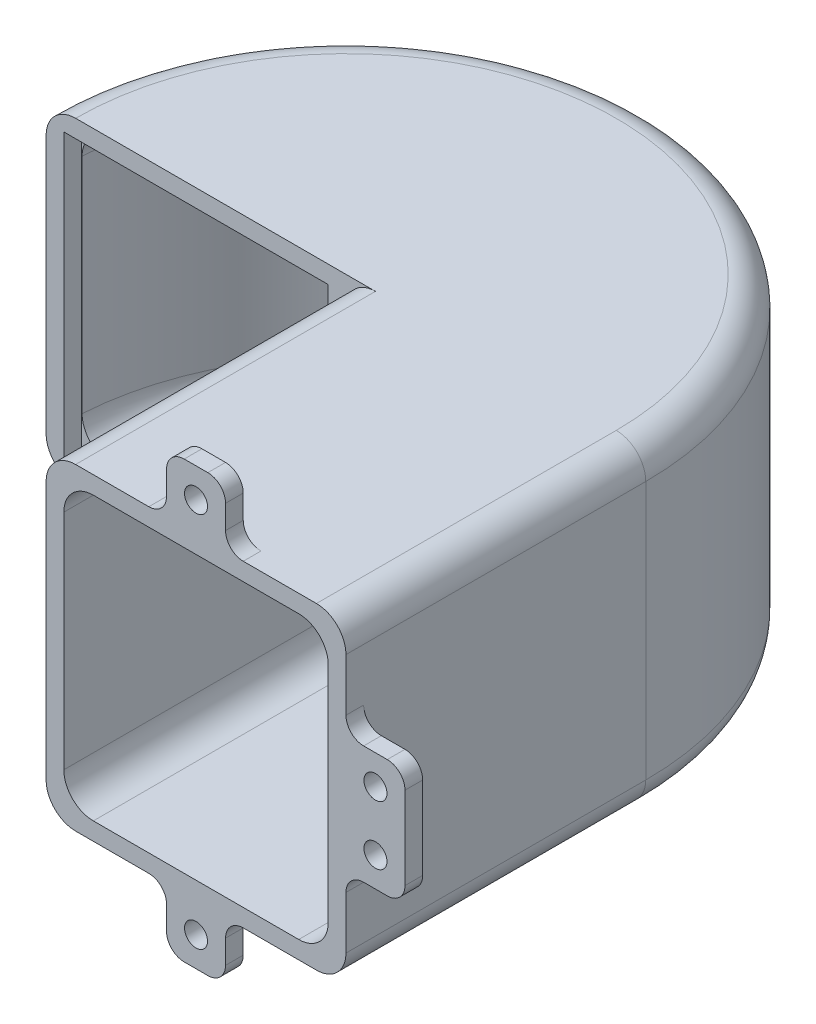
from build123d import *

# Parameters (mm, degrees)
BOSS_EXTRUDE1_DEPTH              = 50.8
CUT_EXTRUDE1_DEPTH               = 47.8
BOSS_EXTRUDE2_DEPTH              = 3
SKETCH4_W                        = 44.8
SKETCH4_H                        = 47.8
CUT_EXTRUDE2_DEPTH               = 3
SKETCH5_W                        = 44.8
SKETCH5_H                        = 47.8
CUT_EXTRUDE3_DEPTH               = 3
SKETCH6_W                        = 10
SKETCH6_H                        = 10
SKETCH6_H_2                      = 20
BOSS_EXTRUDE3_DEPTH              = 3
FILLET1_R                        = 5
FILLET2_R                        = 3
M3_5_CLEARANCE_HOLE2_D           = 3.9
M3_5_CLEARANCE_HOLE2_CSINK_D     = 3.95
M3_5_CLEARANCE_HOLE2_CSINK_ANGLE = 90


with BuildPart() as part:
    # Sketch1 → Boss-Extrude1 (new body)
    with BuildSketch(Plane(origin=(0, 0, 0), x_dir=(1, 0, 0), z_dir=(0, 1, 0))):
        with BuildLine():
            Line((0, 0), (0, 50.8))
            Line((0, 50.8), (-50.8, 50.8))
            ThreePointArc((-50.8, 50.8), (0, 101.6), (50.8, 50.8))
            Line((50.8, 50.8), (50.8, 0))
            Line((50.8, 0), (0, 0))
        make_face()
    extrude(amount=BOSS_EXTRUDE1_DEPTH)

    # Sketch2 → Cut-Extrude1 (cut)
    with BuildSketch(Plane(origin=(0, 50.8, 0), x_dir=(1, 0, 0), z_dir=(0, 1, 0))):
        with BuildLine():
            Line((3, 3), (47.8, 3))
            Line((47.8, 3), (47.8, 50.8))
            ThreePointArc((47.8, 50.8), (1.500739839, 98.576435404), (-47.705764851, 53.8))
            Line((-47.705764851, 53.8), (3, 53.8))
            Line((3, 53.8), (3, 3))
        make_face()
    extrude(amount=-CUT_EXTRUDE1_DEPTH, mode=Mode.SUBTRACT)

    # Sketch3 → Boss-Extrude2 (add)
    with BuildSketch(Plane(origin=(0, 50.8, 0), x_dir=(1, 0, 0), z_dir=(0, 1, 0))):
        with BuildLine():
            Line((0, 50.8), (0, 0))
            Line((0, 0), (50.8, 0))
            Line((50.8, 0), (50.8, 50.8))
            ThreePointArc((50.8, 50.8), (0, 101.6), (-50.8, 50.8))
            Line((-50.8, 50.8), (0, 50.8))
        make_face()
    extrude(amount=BOSS_EXTRUDE2_DEPTH)

    # Sketch4 → Cut-Extrude2 (cut)
    with BuildSketch(Plane.XY):
        with Locations((25.4, 26.9)):
            Rectangle(SKETCH4_W, SKETCH4_H)
    extrude(amount=-CUT_EXTRUDE2_DEPTH, mode=Mode.SUBTRACT)

    # Sketch5 → Cut-Extrude3 (cut)
    with BuildSketch(Plane.XY.offset(-50.8)):
        with Locations((-25.4, 26.9)):
            Rectangle(SKETCH5_W, SKETCH5_H)
    extrude(amount=-CUT_EXTRUDE3_DEPTH, mode=Mode.SUBTRACT)

    # Sketch6 → Boss-Extrude3 (add)
    with BuildSketch(Plane.XY):
        with Locations((25.4, 58.8)):
            Rectangle(SKETCH6_W, SKETCH6_H)
        with Locations((55.8, 26.9)):
            Rectangle(SKETCH6_W, SKETCH6_H_2)
        with Locations((25.4, -5)):
            Rectangle(SKETCH6_W, SKETCH6_H)
    extrude(amount=-BOSS_EXTRUDE3_DEPTH)

    # Fillet1
    fillet1_edges = [part.edges().sort_by_distance(p)[0] for p in [
        (3, 50.8, -26.9),
        (47.8, 50.8, -25.4),
        (1.500739839, 50.8, -98.576435404),
        (3, 3, -26.9),
        (1.500739839, 3, -98.576435404),
        (47.8, 3, -25.4),
        (0, 53.8, -25.4),
        (50.8, 53.8, -25.4),
        (0, 53.8, -101.6),
        (0, 0, -25.4),
        (0, 0, -101.6),
        (50.8, 0, -25.4),
    ]]
    fillet(fillet1_edges, radius=FILLET1_R)

    # Fillet2
    fillet2_edges = [part.edges().sort_by_distance(p)[0] for p in [
        (30.4, 0, -1.5),
        (30.4, -10, -1.5),
        (20.4, -10, -1.5),
        (20.4, 0, -1.5),
        (20.4, 53.8, -1.5),
        (20.4, 63.8, -1.5),
        (30.4, 63.8, -1.5),
        (30.4, 53.8, -1.5),
        (50.8, 16.9, -1.5),
        (50.8, 36.9, -1.5),
        (60.8, 36.9, -1.5),
        (60.8, 16.9, -1.5),
    ]]
    fillet(fillet2_edges, radius=FILLET2_R)

    # M3.5 Clearance Hole2 (through all)
    with Locations(Plane(origin=(0, 0, -3), x_dir=(-1, 0, 0), z_dir=(0, 0, -1))):
        with Locations((-55.8, 31.9), (-55.8, 21.9), (-25.4, 58.8), (-25.4, -5)):
            CounterSinkHole(M3_5_CLEARANCE_HOLE2_D / 2, M3_5_CLEARANCE_HOLE2_CSINK_D / 2, counter_sink_angle=M3_5_CLEARANCE_HOLE2_CSINK_ANGLE)


solid = part.part
